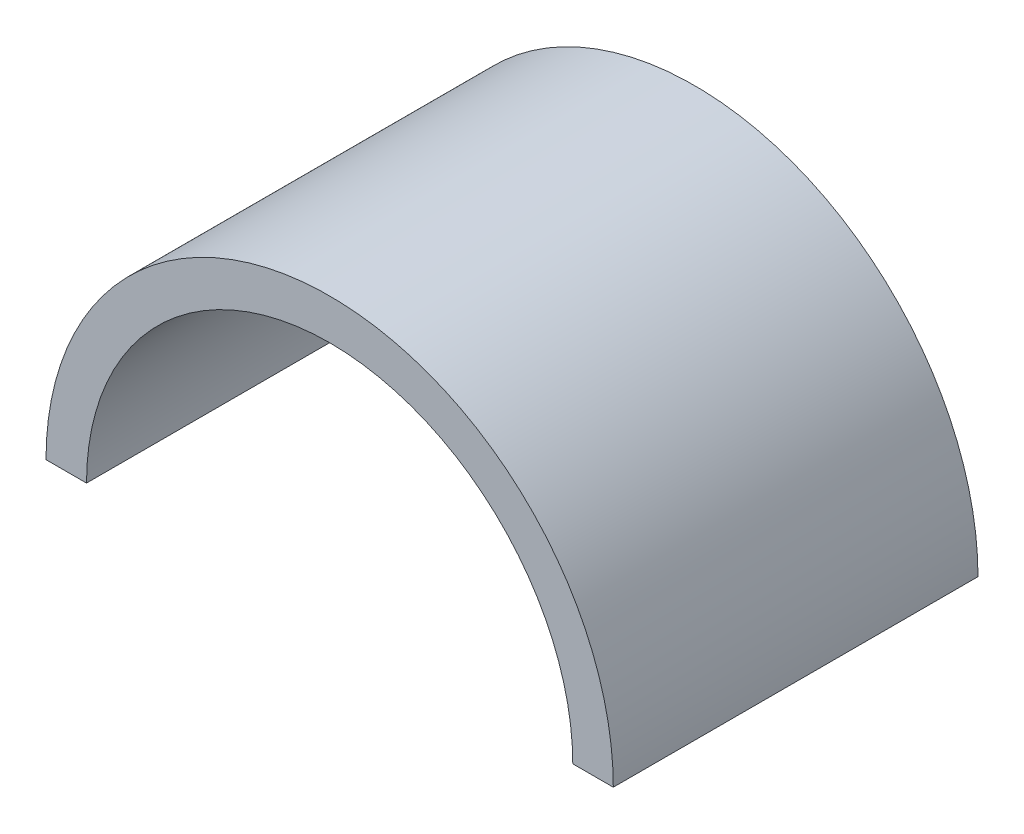
from build123d import *

# Parameters (mm, degrees)
BOSS_EXTRUDE1_DEPTH = 9


with BuildPart() as part:
    # Sketch1 → Boss-Extrude1 (new body)
    with BuildSketch(Plane.XY):
        with BuildLine():
            Line((6, 0), (7, 0))
            ThreePointArc((7, 0), (0, 7), (-7, 0))
            Line((-7, 0), (-6, 0))
            ThreePointArc((-6, 0), (0, 6), (6, 0))
        make_face()
    extrude(amount=BOSS_EXTRUDE1_DEPTH)


solid = part.part
